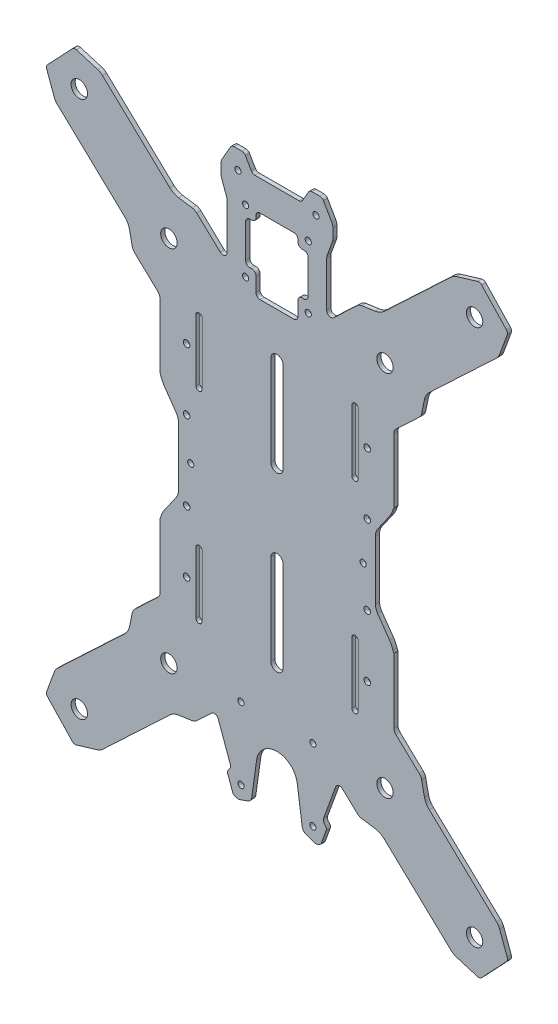
from build123d import *

# Parameters (mm, degrees)
MODEL_R             = 1.5
MODEL_R_2           = 4
BOSS_EXTRUDE1_DEPTH = 2
CUT_EXTRUDE1_START  = -2
SKETCH1_W           = 5.446932399
SKETCH1_H           = 81.038579897
SKETCH1_W_2         = 6.227337796
CUT_EXTRUDE1_DEPTH  = 2
CUT_EXTRUDE2_REACH  = 4
SKETCH4_R           = 1.6


with BuildPart() as part:
    # Model → Boss-Extrude1 (new body)
    with BuildSketch(Plane.XY):
        with BuildLine():
            Line((200.412741898, 281.313149756), (207.019417582, 282.280309624))
            ThreePointArc((207.019417582, 282.280309624), (209.346062513, 282.995121659), (211.350075005, 284.376485771))
            Line((211.350075005, 284.376485771), (244.129053352, 315.296551711))
            ThreePointArc((244.129053352, 315.296551711), (245.241966673, 316.125703781), (246.515608428, 316.676980382))
            Line((246.515608428, 316.676980382), (256.822115777, 319.781518108))
            ThreePointArc((256.822115777, 319.781518108), (257.915045318, 319.798780278), (258.853822051, 319.238877422))
            Line((258.853822051, 319.238877422), (270.881078242, 306.488534933))
            ThreePointArc((270.881078242, 306.488534933), (271.385286838, 305.518706556), (271.304323373, 304.428643114))
            Line((271.304323373, 304.428643114), (267.604044674, 294.320716089))
            ThreePointArc((267.604044674, 294.320716089), (266.97943365, 293.081391094), (266.08679354, 292.018725103))
            Line((266.08679354, 292.018725103), (233.307822643, 261.098651713))
            ThreePointArc((233.307822643, 261.098651713), (231.811945064, 259.178604865), (230.962670444, 256.897604591))
            Line((230.962670444, 256.897604591), (229.611880181, 250.358572728))
            ThreePointArc((229.611880181, 250.358572728), (229.187245122, 249.218070958), (228.439307807, 248.258045441))
            Line((228.439307807, 248.258045441), (217.071655242, 237.535050637))
            ThreePointArc((217.071655242, 237.535050637), (216.375596078, 236.54111239), (216.130192427, 235.352756953))
            Line((216.130192427, 235.352756953), (216.130192427, 211.085992432))
            ThreePointArc((216.130192427, 211.085992432), (216.423085646, 210.378887349), (217.130190728, 210.085994131))
            Line((217.130190728, 210.085994131), (219.130191056, 210.085994131))
            ThreePointArc((219.130191056, 210.085994131), (219.837298547, 209.793102229), (220.130193083, 209.085995829))
            Line((220.130193083, 209.085995829), (220.130193083, 206.997061646))
            ThreePointArc((220.130193083, 206.997061646), (219.897158, 206.355372138), (219.306662985, 206.012755135))
            ThreePointArc((219.306662985, 206.012755135), (217.010488019, 204.889950302), (215.650192397, 202.725994205))
            ThreePointArc((215.650192397, 202.725994205), (214.949457219, 200.895279905), (213.960017113, 199.203076339))
            Line((213.960017113, 199.203076339), (208.215280471, 190.998742855))
            ThreePointArc((208.215280471, 190.998742855), (207.407891081, 189.361519051), (207.130192814, 187.557284287))
            Line((207.130192814, 187.557284287), (207.130192814, 158.688374361))
            ThreePointArc((207.130192814, 158.688374361), (207.407891081, 156.884139597), (208.215280471, 155.246915793))
            Line((208.215280471, 155.246915793), (213.960017113, 147.042582309))
            ThreePointArc((213.960017113, 147.042582309), (214.949457219, 145.350378743), (215.650192397, 143.519664444))
            ThreePointArc((215.650192397, 143.519664444), (217.010488019, 141.355708346), (219.306662985, 140.232903514))
            ThreePointArc((219.306662985, 140.232903514), (219.897158001, 139.89028651), (220.130193083, 139.248597002))
            Line((220.130193083, 139.248597002), (220.130193083, 137.159662819))
            ThreePointArc((220.130193083, 137.159662819), (219.837298547, 136.452556419), (219.130191056, 136.159664518))
            Line((219.130191056, 136.159664518), (217.130190728, 136.159664518))
            ThreePointArc((217.130190728, 136.159664518), (216.423085646, 135.866771299), (216.130192427, 135.159666216))
            Line((216.130192427, 135.159666216), (216.130192427, 110.892901695))
            ThreePointArc((216.130192427, 110.892901695), (216.375596078, 109.704546258), (217.071655242, 108.710608012))
            Line((217.071655242, 108.710608012), (228.439307807, 97.987613207))
            ThreePointArc((228.439307807, 97.987613207), (229.187245122, 97.02758769), (229.611880181, 95.887085921))
            Line((229.611880181, 95.887085921), (230.962670444, 89.348054058))
            ThreePointArc((230.962670444, 89.348054058), (231.811945064, 87.067053783), (233.307822643, 85.147006935))
            Line((233.307822643, 85.147006935), (266.08679354, 54.226933545))
            ThreePointArc((266.08679354, 54.226933545), (266.97943365, 53.164267554), (267.604044674, 51.924942559))
            Line((267.604044674, 51.924942559), (271.304323373, 41.817015535))
            ThreePointArc((271.304323373, 41.817015535), (271.385286838, 40.726952092), (270.881078242, 39.757123715))
            Line((270.881078242, 39.757123715), (258.853822051, 27.006781226))
            ThreePointArc((258.853822051, 27.006781226), (257.915045318, 26.44687837), (256.822115777, 26.464140541))
            Line((256.822115777, 26.464140541), (246.515608428, 29.568678266))
            ThreePointArc((246.515608428, 29.568678266), (245.241966673, 30.119954868), (244.129053352, 30.949106938))
            Line((244.129053352, 30.949106938), (211.350075005, 61.869172877))
            ThreePointArc((211.350075005, 61.869172877), (209.346062513, 63.25053699), (207.019417582, 63.965349025))
            Line((207.019417582, 63.965349025), (200.412741898, 64.932508892))
            ThreePointArc((200.412741898, 64.932508892), (199.24942012, 65.28991142), (198.247413186, 65.980589515))
            Line((198.247413186, 65.980589515), (191.012158094, 72.805537409))
            ThreePointArc((191.012158094, 72.805537409), (189.178482522, 73.296740969), (187.76041366, 72.034707791))
            Line((187.76041366, 72.034707791), (181.83126211, 55.744505054))
            ThreePointArc((181.83126211, 55.744505054), (181.741033127, 54.713169482), (182.178559748, 53.774891919))
            Line((182.178559748, 53.774891919), (182.735229878, 53.111477321))
            ThreePointArc((182.735229878, 53.111477321), (183.172757635, 52.173195972), (183.082525654, 51.141856736))
            Line((183.082525654, 51.141856736), (180.712941138, 44.631472355))
            ThreePointArc((180.712941138, 44.631472355), (180.11912963, 43.783427967), (179.180852173, 43.345904476))
            Line((179.180852173, 43.345904476), (177.86146052, 43.113252646))
            ThreePointArc((177.86146052, 43.113252646), (177.60065559, 43.101868291), (177.345790936, 43.158373362))
            Line((177.345790936, 43.158373362), (173.367758317, 44.606259591))
            ThreePointArc((173.367758317, 44.606259591), (172.062380787, 45.537377253), (171.42301522, 47.007820135))
            Line((171.42301522, 47.007820135), (169.03287269, 64.014560109))
            ThreePointArc((169.03287269, 64.014560109), (159.130192397, 72.622826292), (149.227512104, 64.014560109))
            Line((149.227512104, 64.014560109), (146.837369574, 47.007820135))
            ThreePointArc((146.837369574, 47.007820135), (146.198004008, 45.537377253), (144.892626477, 44.606259591))
            Line((144.892626477, 44.606259591), (140.914593859, 43.158373362))
            ThreePointArc((140.914593859, 43.158373362), (140.659729204, 43.101868291), (140.398924274, 43.113252646))
            Line((140.398924274, 43.113252646), (139.079532621, 43.345904476))
            ThreePointArc((139.079532621, 43.345904476), (138.141255164, 43.783427967), (137.547443656, 44.631472355))
            Line((137.547443656, 44.631472355), (135.177859141, 51.141856736))
            ThreePointArc((135.177859141, 51.141856736), (135.087627159, 52.173195972), (135.525154917, 53.111477321))
            Line((135.525154917, 53.111477321), (136.081825046, 53.774891919))
            ThreePointArc((136.081825046, 53.774891919), (136.519351668, 54.713169482), (136.429122685, 55.744505054))
            Line((136.429122685, 55.744505054), (130.499971135, 72.034707791))
            ThreePointArc((130.499971135, 72.034707791), (129.081902272, 73.296740969), (127.2482267, 72.805537409))
            Line((127.2482267, 72.805537409), (120.012971608, 65.980589515))
            ThreePointArc((120.012971608, 65.980589515), (119.010964675, 65.28991142), (117.847642897, 64.932508892))
            Line((117.847642897, 64.932508892), (111.240967212, 63.965349025))
            ThreePointArc((111.240967212, 63.965349025), (108.914322282, 63.25053699), (106.91030979, 61.869172877))
            Line((106.91030979, 61.869172877), (74.131331442, 30.949106938))
            ThreePointArc((74.131331442, 30.949106938), (73.018418122, 30.119954868), (71.744776366, 29.568678266))
            Line((71.744776366, 29.568678266), (61.438269017, 26.464140541))
            ThreePointArc((61.438269017, 26.464140541), (60.345339477, 26.44687837), (59.406562744, 27.006781226))
            Line((59.406562744, 27.006781226), (47.379306553, 39.757123715))
            ThreePointArc((47.379306553, 39.757123715), (46.875097957, 40.726952092), (46.956061421, 41.817015535))
            Line((46.956061421, 41.817015535), (50.65634012, 51.924942559))
            ThreePointArc((50.65634012, 51.924942559), (51.280951144, 53.164267554), (52.173591254, 54.226933545))
            Line((52.173591254, 54.226933545), (84.952562152, 85.147006935))
            ThreePointArc((84.952562152, 85.147006935), (86.44843973, 87.067053783), (87.297714351, 89.348054058))
            Line((87.297714351, 89.348054058), (88.648504613, 95.887085921))
            ThreePointArc((88.648504613, 95.887085921), (89.073139673, 97.02758769), (89.821076987, 97.987613207))
            Line((89.821076987, 97.987613207), (101.188729553, 108.710608012))
            ThreePointArc((101.188729553, 108.710608012), (101.884788716, 109.704546258), (102.130192367, 110.892901695))
            Line((102.130192367, 110.892901695), (102.130192367, 135.159666216))
            ThreePointArc((102.130192367, 135.159666216), (101.837299149, 135.866771299), (101.130194066, 136.159664518))
            Line((101.130194066, 136.159664518), (99.130193738, 136.159664518))
            ThreePointArc((99.130193738, 136.159664518), (98.423086248, 136.452556419), (98.130191712, 137.159662819))
            Line((98.130191712, 137.159662819), (98.130191712, 139.248597002))
            ThreePointArc((98.130191712, 139.248597002), (98.363226794, 139.89028651), (98.953721809, 140.232903514))
            ThreePointArc((98.953721809, 140.232903514), (101.249896776, 141.355708346), (102.610192397, 143.519664443))
            ThreePointArc((102.610192397, 143.519664443), (103.310927575, 145.350378743), (104.300367681, 147.042582309))
            Line((104.300367681, 147.042582309), (110.045104323, 155.246915793))
            ThreePointArc((110.045104323, 155.246915793), (110.852493714, 156.884139597), (111.13019198, 158.688374361))
            Line((111.13019198, 158.688374361), (111.13019198, 187.557284287))
            ThreePointArc((111.13019198, 187.557284287), (110.852493714, 189.361519051), (110.045104323, 190.998742855))
            Line((110.045104323, 190.998742855), (104.300367681, 199.203076339))
            ThreePointArc((104.300367681, 199.203076339), (103.310927575, 200.895279905), (102.610192397, 202.725994205))
            ThreePointArc((102.610192397, 202.725994205), (101.249896776, 204.889950302), (98.953721809, 206.012755135))
            ThreePointArc((98.953721809, 206.012755135), (98.363226794, 206.355372138), (98.130191712, 206.997061646))
            Line((98.130191712, 206.997061646), (98.130191712, 209.085995829))
            ThreePointArc((98.130191712, 209.085995829), (98.423086248, 209.793102229), (99.130193738, 210.085994131))
            Line((99.130193738, 210.085994131), (101.130194066, 210.085994131))
            ThreePointArc((101.130194066, 210.085994131), (101.837299149, 210.378887349), (102.130192367, 211.085992432))
            Line((102.130192367, 211.085992432), (102.130192367, 235.352756953))
            ThreePointArc((102.130192367, 235.352756953), (101.884788716, 236.54111239), (101.188729553, 237.535050637))
            Line((101.188729553, 237.535050637), (89.821076987, 248.258045441))
            ThreePointArc((89.821076987, 248.258045441), (89.073139673, 249.218070958), (88.648504613, 250.358572728))
            Line((88.648504613, 250.358572728), (87.297714351, 256.897604591))
            ThreePointArc((87.297714351, 256.897604591), (86.44843973, 259.178604865), (84.952562152, 261.098651713))
            Line((84.952562152, 261.098651713), (52.173591254, 292.018725103))
            ThreePointArc((52.173591254, 292.018725103), (51.280951144, 293.081391094), (50.65634012, 294.320716089))
            Line((50.65634012, 294.320716089), (46.956061421, 304.428643114))
            ThreePointArc((46.956061421, 304.428643114), (46.875097957, 305.518706556), (47.379306553, 306.488534933))
            Line((47.379306553, 306.488534933), (59.406562744, 319.238877422))
            ThreePointArc((59.406562744, 319.238877422), (60.345339477, 319.798780278), (61.438269017, 319.781518108))
            Line((61.438269017, 319.781518108), (71.744776366, 316.676980382))
            ThreePointArc((71.744776366, 316.676980382), (73.018418122, 316.125703781), (74.131331442, 315.296551711))
            Line((74.131331442, 315.296551711), (106.91030979, 284.376485771))
            ThreePointArc((106.91030979, 284.376485771), (108.914322282, 282.995121659), (111.240967212, 282.280309624))
            Line((111.240967212, 282.280309624), (117.847642897, 281.313149756))
            ThreePointArc((117.847642897, 281.313149756), (119.010964675, 280.955747228), (120.012971608, 280.265069133))
            Line((120.012971608, 280.265069133), (131.507833524, 269.422082728))
            ThreePointArc((131.507833524, 269.422082728), (133.67243115, 269.040550313), (134.880191682, 270.876950151))
            Line((134.880191682, 270.876950151), (134.880191682, 292.844689018))
            ThreePointArc((134.880191682, 292.844689018), (134.819423011, 293.539282981), (134.638962371, 294.212772077))
            Line((134.638962371, 294.212772077), (132.121422363, 301.129660136))
            ThreePointArc((132.121422363, 301.129660136), (131.94096237, 301.803145563), (131.880193053, 302.497735745))
            Line((131.880193053, 302.497735745), (131.880193053, 307.258924967))
            ThreePointArc((131.880193053, 307.258924967), (132.016490923, 308.294195505), (132.416090964, 309.258914119))
            Line((132.416090964, 309.258914119), (136.498994229, 316.330707199))
            ThreePointArc((136.498994229, 316.330707199), (137.231044932, 317.062759296), (138.231045602, 317.330709225))
            Line((138.231045602, 317.330709225), (142.029338552, 317.330709225))
            ThreePointArc((142.029338552, 317.330709225), (143.029339222, 317.062759296), (143.761389924, 316.330707199))
            Line((143.761389924, 316.330707199), (146.648141591, 311.330711967))
            ThreePointArc((146.648141591, 311.330711967), (147.38019189, 310.598660102), (148.380192032, 310.33070994))
            Line((148.380192032, 310.33070994), (169.880192762, 310.33070994))
            ThreePointArc((169.880192762, 310.33070994), (170.880192904, 310.598660102), (171.612243203, 311.330711967))
            Line((171.612243203, 311.330711967), (174.49899487, 316.330707199))
            ThreePointArc((174.49899487, 316.330707199), (175.231045573, 317.062759296), (176.231046243, 317.330709225))
            Line((176.231046243, 317.330709225), (180.029339193, 317.330709225))
            ThreePointArc((180.029339193, 317.330709225), (181.029339863, 317.062759296), (181.761390565, 316.330707199))
            Line((181.761390565, 316.330707199), (185.844293831, 309.258914119))
            ThreePointArc((185.844293831, 309.258914119), (186.243893872, 308.294195505), (186.380191742, 307.258924967))
            Line((186.380191742, 307.258924967), (186.380191742, 302.497735745))
            ThreePointArc((186.380191742, 302.497735745), (186.319422424, 301.803145563), (186.138962431, 301.129660136))
            Line((186.138962431, 301.129660136), (183.621422423, 294.212772077))
            ThreePointArc((183.621422423, 294.212772077), (183.440961783, 293.539282981), (183.380193112, 292.844689018))
            Line((183.380193112, 292.844689018), (183.380193112, 270.876950151))
            ThreePointArc((183.380193112, 270.876950151), (184.587953644, 269.040550313), (186.752551271, 269.422082728))
            Line((186.752551271, 269.422082728), (198.247413186, 280.265069133))
            ThreePointArc((198.247413186, 280.265069133), (199.24942012, 280.955747228), (200.412741898, 281.313149756))
        make_face()
        with Locations((174.380192397, 265.122829324)):
            Circle(MODEL_R, mode=Mode.SUBTRACT)
        with Locations((143.880192397, 295.622829324)):
            Circle(MODEL_R, mode=Mode.SUBTRACT)
        with Locations((176.630192397, 84.767778966)):
            Circle(MODEL_R, mode=Mode.SUBTRACT)
        with Locations((141.630192397, 49.767778966)):
            Circle(MODEL_R, mode=Mode.SUBTRACT)
        with Locations((106.49549278, 262.77260343)):
            Circle(MODEL_R_2, mode=Mode.SUBTRACT)
        with Locations((62.849554611, 303.943370745)):
            Circle(MODEL_R_2, mode=Mode.SUBTRACT)
        with Locations((106.49549278, 83.473055219)):
            Circle(MODEL_R_2, mode=Mode.SUBTRACT)
        with Locations((62.849554611, 42.302287903)):
            Circle(MODEL_R_2, mode=Mode.SUBTRACT)
        with Locations((255.410830183, 42.302287903)):
            Circle(MODEL_R_2, mode=Mode.SUBTRACT)
        with Locations((211.764892015, 83.473055219)):
            Circle(MODEL_R_2, mode=Mode.SUBTRACT)
        with Locations((255.410830183, 303.943370745)):
            Circle(MODEL_R_2, mode=Mode.SUBTRACT)
        with Locations((211.764892015, 262.77260343)):
            Circle(MODEL_R_2, mode=Mode.SUBTRACT)
        with Locations((176.630192397, 49.767778966)):
            Circle(MODEL_R, mode=Mode.SUBTRACT)
        with Locations((141.630192397, 84.767778966)):
            Circle(MODEL_R, mode=Mode.SUBTRACT)
        with Locations((174.380192397, 295.622829324)):
            Circle(MODEL_R, mode=Mode.SUBTRACT)
        with Locations((143.880192397, 265.122829324)):
            Circle(MODEL_R, mode=Mode.SUBTRACT)
        with Locations((201.130192397, 173.122829324)):
            Circle(MODEL_R, mode=Mode.SUBTRACT)
        with Locations((117.130192397, 173.122829324)):
            Circle(MODEL_R, mode=Mode.SUBTRACT)
        with Locations((178.130192397, 308.330714568)):
            Circle(MODEL_R, mode=Mode.SUBTRACT)
        with Locations((140.130192397, 308.330714568)):
            Circle(MODEL_R, mode=Mode.SUBTRACT)
        with BuildLine():
            Line((119.630190579, 109.122826284), (119.630190579, 139.122827476))
            ThreePointArc((119.630190579, 139.122827476), (121.130191756, 140.622828654), (122.630192934, 139.122827476))
            Line((122.630192934, 139.122827476), (122.630192934, 109.122826284))
            ThreePointArc((122.630192934, 109.122826284), (121.130191756, 107.622825107), (119.630190579, 109.122826284))
        make_face(mode=Mode.SUBTRACT)
        with BuildLine():
            Line((198.630194215, 237.122832364), (198.630194215, 207.122831172))
            ThreePointArc((198.630194215, 207.122831172), (197.130193038, 205.622829995), (195.630191861, 207.122831172))
            Line((195.630191861, 207.122831172), (195.630191861, 237.122832364))
            ThreePointArc((195.630191861, 237.122832364), (197.130193038, 238.622833541), (198.630194215, 237.122832364))
        make_face(mode=Mode.SUBTRACT)
        with BuildLine():
            Line((146.880192718, 270.122832185), (145.880192554, 270.122832185))
            ThreePointArc((145.880192554, 270.122832185), (144.465979981, 270.708617306), (143.880192226, 272.122828788))
            Line((143.880192226, 272.122828788), (143.880192226, 288.622832424))
            ThreePointArc((143.880192226, 288.622832424), (144.465979981, 290.037043906), (145.880192554, 290.622829026))
            Line((145.880192554, 290.622829026), (146.880192718, 290.622829026))
            ThreePointArc((146.880192718, 290.622829026), (148.294404689, 291.208614476), (148.880192114, 292.622825629))
            Line((148.880192114, 292.622825629), (148.880192114, 293.622827655))
            ThreePointArc((148.880192114, 293.622827655), (149.465977235, 295.037043954), (150.880192442, 295.622831708))
            Line((150.880192442, 295.622831708), (167.380192352, 295.622831708))
            ThreePointArc((167.380192352, 295.622831708), (168.79440756, 295.037043954), (169.38019268, 293.622827655))
            Line((169.38019268, 293.622827655), (169.38019268, 292.622825629))
            ThreePointArc((169.38019268, 292.622825629), (169.965980106, 291.208614476), (171.380192077, 290.622829026))
            Line((171.380192077, 290.622829026), (172.380192241, 290.622829026))
            ThreePointArc((172.380192241, 290.622829026), (173.794404814, 290.037043906), (174.380192569, 288.622832424))
            Line((174.380192569, 288.622832424), (174.380192569, 272.122828788))
            ThreePointArc((174.380192569, 272.122828788), (173.794404814, 270.708617306), (172.380192241, 270.122832185))
            Line((172.380192241, 270.122832185), (171.380192077, 270.122832185))
            ThreePointArc((171.380192077, 270.122832185), (169.965977472, 269.537044101), (169.38019268, 268.122828132))
            Line((169.38019268, 268.122828132), (169.38019268, 261.122828847))
            ThreePointArc((169.38019268, 261.122828847), (168.794404926, 259.708617365), (167.380192352, 259.122832245))
            Line((167.380192352, 259.122832245), (150.880192442, 259.122832245))
            ThreePointArc((150.880192442, 259.122832245), (149.465979869, 259.708617365), (148.880192114, 261.122828847))
            Line((148.880192114, 261.122828847), (148.880192114, 268.122828132))
            ThreePointArc((148.880192114, 268.122828132), (148.294407323, 269.537044101), (146.880192718, 270.122832185))
        make_face(mode=Mode.SUBTRACT)
        with BuildLine():
            Line((162.130192423, 237.122832364), (162.130192423, 193.122828877))
            ThreePointArc((162.130192423, 193.122828877), (159.130192397, 190.122828851), (156.130192371, 193.122828877))
            Line((156.130192371, 193.122828877), (156.130192371, 237.122832364))
            ThreePointArc((156.130192371, 237.122832364), (159.130192397, 240.12283239), (162.130192423, 237.122832364))
        make_face(mode=Mode.SUBTRACT)
        with BuildLine():
            Line((156.130192371, 109.122826284), (156.130192371, 153.122829771))
            ThreePointArc((156.130192371, 153.122829771), (159.130192397, 156.122829797), (162.130192423, 153.122829771))
            Line((162.130192423, 153.122829771), (162.130192423, 109.122826284))
            ThreePointArc((162.130192423, 109.122826284), (159.130192397, 106.122826258), (156.130192371, 109.122826284))
        make_face(mode=Mode.SUBTRACT)
        with BuildLine():
            Line((122.630192934, 237.122832364), (122.630192934, 207.122831172))
            ThreePointArc((122.630192934, 207.122831172), (121.130191756, 205.622829995), (119.630190579, 207.122831172))
            Line((119.630190579, 207.122831172), (119.630190579, 237.122832364))
            ThreePointArc((119.630190579, 237.122832364), (121.130191756, 238.622833541), (122.630192934, 237.122832364))
        make_face(mode=Mode.SUBTRACT)
        with BuildLine():
            Line((195.630191861, 109.122826284), (195.630191861, 139.122827476))
            ThreePointArc((195.630191861, 139.122827476), (197.130193038, 140.622828654), (198.630194215, 139.122827476))
            Line((198.630194215, 139.122827476), (198.630194215, 109.122826284))
            ThreePointArc((198.630194215, 109.122826284), (197.130193038, 107.622825107), (195.630191861, 109.122826284))
        make_face(mode=Mode.SUBTRACT)
    extrude(amount=BOSS_EXTRUDE1_DEPTH)

    # Sketch1 → Cut-Extrude1 (cut)
    with BuildSketch(Plane.XY.offset(2).offset(CUT_EXTRUDE1_START)):
        with Locations((218.853658627, 174.202991133)):
            Rectangle(SKETCH1_W, SKETCH1_H)
        with Locations((99.016523469, 174.202991133)):
            Rectangle(SKETCH1_W_2, SKETCH1_H)
    extrude(amount=CUT_EXTRUDE1_DEPTH, mode=Mode.SUBTRACT)

    # Sketch4 → Cut-Extrude2 (cut, up to next)
    with BuildSketch(Plane(origin=(0, 0, 0), x_dir=(-1, 0, 0), z_dir=(0, 0, -1)), mode=Mode.PRIVATE) as cut_extrude2_sk1:
        with Locations((-203.130226281, 124.150246159)):
            Circle(SKETCH4_R)
    cut_extrude2_tool1 = extrude(cut_extrude2_sk1.sketch, amount=-CUT_EXTRUDE2_REACH, mode=Mode.PRIVATE) & part.part
    add(cut_extrude2_tool1.solids().sort_by_distance((203.130226, 124.150246, 0))[0], mode=Mode.SUBTRACT)
    # Sketch4 → Cut-Extrude2 (cut, up to next)
    with BuildSketch(Plane(origin=(0, 0, 0), x_dir=(-1, 0, 0), z_dir=(0, 0, -1)), mode=Mode.PRIVATE) as cut_extrude2_sk2:
        with Locations((-203.130226281, 154.150246159)):
            Circle(SKETCH4_R)
    cut_extrude2_tool2 = extrude(cut_extrude2_sk2.sketch, amount=-CUT_EXTRUDE2_REACH, mode=Mode.PRIVATE) & part.part
    add(cut_extrude2_tool2.solids().sort_by_distance((203.130226, 154.150246, 0))[0], mode=Mode.SUBTRACT)
    # Sketch4 → Cut-Extrude2 (cut, up to next)
    with BuildSketch(Plane(origin=(0, 0, 0), x_dir=(-1, 0, 0), z_dir=(0, 0, -1)), mode=Mode.PRIVATE) as cut_extrude2_sk3:
        with Locations((-203.130226281, 192.650288311)):
            Circle(SKETCH4_R)
    cut_extrude2_tool3 = extrude(cut_extrude2_sk3.sketch, amount=-CUT_EXTRUDE2_REACH, mode=Mode.PRIVATE) & part.part
    add(cut_extrude2_tool3.solids().sort_by_distance((203.130226, 192.650288, 0))[0], mode=Mode.SUBTRACT)
    # Sketch4 → Cut-Extrude2 (cut, up to next)
    with BuildSketch(Plane(origin=(0, 0, 0), x_dir=(-1, 0, 0), z_dir=(0, 0, -1)), mode=Mode.PRIVATE) as cut_extrude2_sk4:
        with Locations((-203.130226281, 222.650288311)):
            Circle(SKETCH4_R)
    cut_extrude2_tool4 = extrude(cut_extrude2_sk4.sketch, amount=-CUT_EXTRUDE2_REACH, mode=Mode.PRIVATE) & part.part
    add(cut_extrude2_tool4.solids().sort_by_distance((203.130226, 222.650288, 0))[0], mode=Mode.SUBTRACT)
    # Sketch4 → Cut-Extrude2 (cut, up to next)
    with BuildSketch(Plane(origin=(0, 0, 0), x_dir=(-1, 0, 0), z_dir=(0, 0, -1)), mode=Mode.PRIVATE) as cut_extrude2_sk5:
        with Locations((-115.130244662, 222.650288311)):
            Circle(SKETCH4_R)
    cut_extrude2_tool5 = extrude(cut_extrude2_sk5.sketch, amount=-CUT_EXTRUDE2_REACH, mode=Mode.PRIVATE) & part.part
    add(cut_extrude2_tool5.solids().sort_by_distance((115.130245, 222.650288, 0))[0], mode=Mode.SUBTRACT)
    # Sketch4 → Cut-Extrude2 (cut, up to next)
    with BuildSketch(Plane(origin=(0, 0, 0), x_dir=(-1, 0, 0), z_dir=(0, 0, -1)), mode=Mode.PRIVATE) as cut_extrude2_sk6:
        with Locations((-115.130244662, 192.650288311)):
            Circle(SKETCH4_R)
    cut_extrude2_tool6 = extrude(cut_extrude2_sk6.sketch, amount=-CUT_EXTRUDE2_REACH, mode=Mode.PRIVATE) & part.part
    add(cut_extrude2_tool6.solids().sort_by_distance((115.130245, 192.650288, 0))[0], mode=Mode.SUBTRACT)
    # Sketch4 → Cut-Extrude2 (cut, up to next)
    with BuildSketch(Plane(origin=(0, 0, 0), x_dir=(-1, 0, 0), z_dir=(0, 0, -1)), mode=Mode.PRIVATE) as cut_extrude2_sk7:
        with Locations((-115.130192367, 154.150288311)):
            Circle(SKETCH4_R)
    cut_extrude2_tool7 = extrude(cut_extrude2_sk7.sketch, amount=-CUT_EXTRUDE2_REACH, mode=Mode.PRIVATE) & part.part
    add(cut_extrude2_tool7.solids().sort_by_distance((115.130192, 154.150288, 0))[0], mode=Mode.SUBTRACT)
    # Sketch4 → Cut-Extrude2 (cut, up to next)
    with BuildSketch(Plane(origin=(0, 0, 0), x_dir=(-1, 0, 0), z_dir=(0, 0, -1)), mode=Mode.PRIVATE) as cut_extrude2_sk8:
        with Locations((-115.130192367, 124.150288311)):
            Circle(SKETCH4_R)
    cut_extrude2_tool8 = extrude(cut_extrude2_sk8.sketch, amount=-CUT_EXTRUDE2_REACH, mode=Mode.PRIVATE) & part.part
    add(cut_extrude2_tool8.solids().sort_by_distance((115.130192, 124.150288, 0))[0], mode=Mode.SUBTRACT)


solid = part.part
